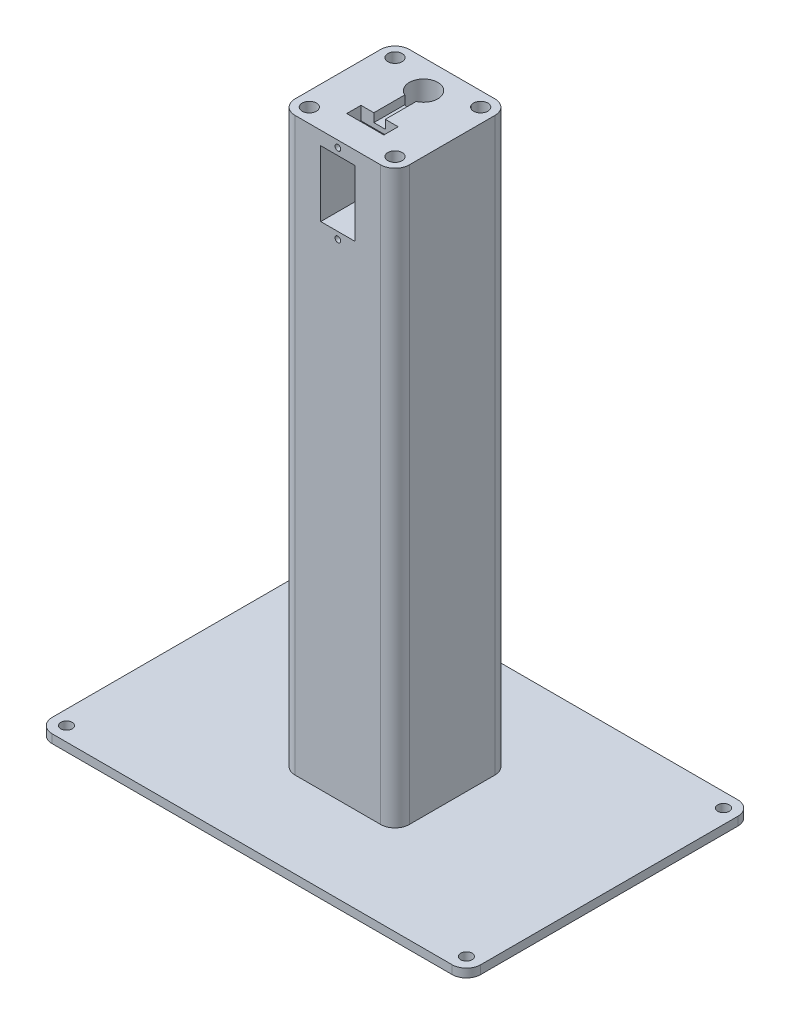
from build123d import *

# Parameters (mm, degrees)
SKETCH1_W               = 40
SKETCH1_H               = 40
BOSS_EXTRUDE1_DEPTH     = 200
SKETCH2_W               = 12
SKETCH2_H               = 23
CUT_EXTRUDE1_DEPTH      = 15.9
SKETCH3_R               = 1
CUT_EXTRUDE2_DEPTH      = 4
SKETCH4_R               = 5
CUT_EXTRUDE3_DEPTH      = 201
SKETCH5_W               = 13
SKETCH5_H               = 5
CUT_EXTRUDE4_DEPTH      = 4.7
SKETCH6_W               = 4
SKETCH6_H               = 10.817424305
CUT_EXTRUDE5_DEPTH      = 3
FILLET1_R               = 5
SKETCH7_W               = 150
SKETCH7_H               = 100
BOSS_EXTRUDE2_DEPTH     = 3
SKETCH9_R               = 5
CUT_EXTRUDE6_DEPTH      = 3
SKETCH10_R              = 2
CUT_EXTRUDE7_DEPTH      = 4
MIRROR2_COPY_1_SKETCH_R = 2
MIRROR2_COPY_1_DEPTH    = 4
SKETCH11_R              = 2.5
CUT_EXTRUDE8_DEPTH      = 5
MIRROR4_COPY_1_SKETCH_R = 2.5
MIRROR4_COPY_1_DEPTH    = 5
FILLET2_R               = 5


with BuildPart() as part:
    # Sketch1 → Boss-Extrude1 (new body)
    with BuildSketch(Plane(origin=(0, 0, 0), x_dir=(1, 0, 0), z_dir=(0, 1, 0))):
        with Locations((20, 20)):
            Rectangle(SKETCH1_W, SKETCH1_H)
    extrude(amount=BOSS_EXTRUDE1_DEPTH)

    # Sketch2 → Cut-Extrude1 (cut)
    with BuildSketch(Plane.XY):
        with Locations((20, 183.8)):
            Rectangle(SKETCH2_W, SKETCH2_H)
    extrude(amount=-CUT_EXTRUDE1_DEPTH, mode=Mode.SUBTRACT)

    # Sketch3 → Cut-Extrude2 (cut)
    with BuildSketch(Plane.XY):
        with Locations((20, 197.7)):
            Circle(SKETCH3_R)
        with Locations((20, 169.9)):
            Circle(SKETCH3_R)
    extrude(amount=-CUT_EXTRUDE2_DEPTH, mode=Mode.SUBTRACT)

    # Sketch4 → Cut-Extrude3 (cut, through all)
    with BuildSketch(Plane(origin=(0, 200, 0), x_dir=(1, 0, 0), z_dir=(0, 1, 0))):
        with Locations((20, 30)):
            Circle(SKETCH4_R)
    extrude(amount=-CUT_EXTRUDE3_DEPTH, mode=Mode.SUBTRACT)

    # Sketch5 → Cut-Extrude4 (cut)
    with BuildSketch(Plane(origin=(0, 200, 0), x_dir=(1, 0, 0), z_dir=(0, 1, 0))):
        with Locations((20, 12.1)):
            Rectangle(SKETCH5_W, SKETCH5_H)
    extrude(amount=-CUT_EXTRUDE4_DEPTH, mode=Mode.SUBTRACT)

    # Sketch6 → Cut-Extrude5 (cut)
    with BuildSketch(Plane(origin=(0, 200, 0), x_dir=(1, 0, 0), z_dir=(0, 1, 0))):
        with Locations((20, 20.008712153)):
            Rectangle(SKETCH6_W, SKETCH6_H)
    extrude(amount=-CUT_EXTRUDE5_DEPTH, mode=Mode.SUBTRACT)

    # Fillet1
    fillet1_edges = [part.edges().sort_by_distance(p)[0] for p in [
        (0, 100, -40),
        (40, 100, -40),
        (40, 100, 0),
        (0, 100, 0),
    ]]
    fillet(fillet1_edges, radius=FILLET1_R)

    # Sketch7 → Boss-Extrude2 (add)
    with BuildSketch(Plane.XZ):
        with Locations((20, -20)):
            Rectangle(SKETCH7_W, SKETCH7_H)
    extrude(amount=BOSS_EXTRUDE2_DEPTH)

    # Sketch9 → Cut-Extrude6 (cut)
    with BuildSketch(Plane.XZ.offset(3)):
        with Locations((20, -30)):
            Circle(SKETCH9_R)
    extrude(amount=-CUT_EXTRUDE6_DEPTH, mode=Mode.SUBTRACT)

    # Sketch10 → Cut-Extrude7 (cut, through all)
    with BuildSketch(Plane(origin=(0, 0, 0), x_dir=(1, 0, 0), z_dir=(0, 1, 0))):
        with Locations((-50, 65)):
            Circle(SKETCH10_R)
    cut_extrude7 = extrude(amount=-CUT_EXTRUDE7_DEPTH, mode=Mode.SUBTRACT)

    # Mirror1: Cut-Extrude7 across plane
    add(cut_extrude7.mirror(Plane.ZY.offset(-20)), mode=Mode.SUBTRACT)

    # Mirror2: Cut-Extrude7 across plane
    add(cut_extrude7.mirror(Plane(origin=(0, 0, -20), x_dir=(1, 0, 0), z_dir=(0, 0, -1))), mode=Mode.SUBTRACT)

    # Mirror2 copy 1 sketch → Mirror2 copy 1 (cut, through all)
    with BuildSketch(Plane(origin=(40, 0, -40), x_dir=(-1, 0, 0), z_dir=(0, 1, 0))):
        with Locations((-50, 65)):
            Circle(MIRROR2_COPY_1_SKETCH_R)
    extrude(amount=-MIRROR2_COPY_1_DEPTH, mode=Mode.SUBTRACT)

    # Sketch11 → Cut-Extrude8 (cut)
    with BuildSketch(Plane(origin=(0, 200, 0), x_dir=(1, 0, 0), z_dir=(0, 1, 0))):
        with Locations((5, 35)):
            Circle(SKETCH11_R)
    cut_extrude8 = extrude(amount=-CUT_EXTRUDE8_DEPTH, mode=Mode.SUBTRACT)

    # Mirror3: Cut-Extrude8 across plane
    add(cut_extrude8.mirror(Plane(origin=(0, 0, -20), x_dir=(1, 0, 0), z_dir=(0, 0, -1))), mode=Mode.SUBTRACT)

    # Mirror4: Cut-Extrude8 across plane
    add(cut_extrude8.mirror(Plane.ZY.offset(-20)), mode=Mode.SUBTRACT)

    # Mirror4 copy 1 sketch → Mirror4 copy 1 (cut)
    with BuildSketch(Plane(origin=(40, 200, -40), x_dir=(-1, 0, 0), z_dir=(0, 1, 0))):
        with Locations((5, 35)):
            Circle(MIRROR4_COPY_1_SKETCH_R)
    extrude(amount=-MIRROR4_COPY_1_DEPTH, mode=Mode.SUBTRACT)

    # Fillet2
    fillet2_edges = [part.edges().sort_by_distance(p)[0] for p in [
        (-55, -1.5, 30),
        (-55, -1.5, -70),
        (95, -1.5, -70),
        (95, -1.5, 30),
    ]]
    fillet(fillet2_edges, radius=FILLET2_R)


solid = part.part
